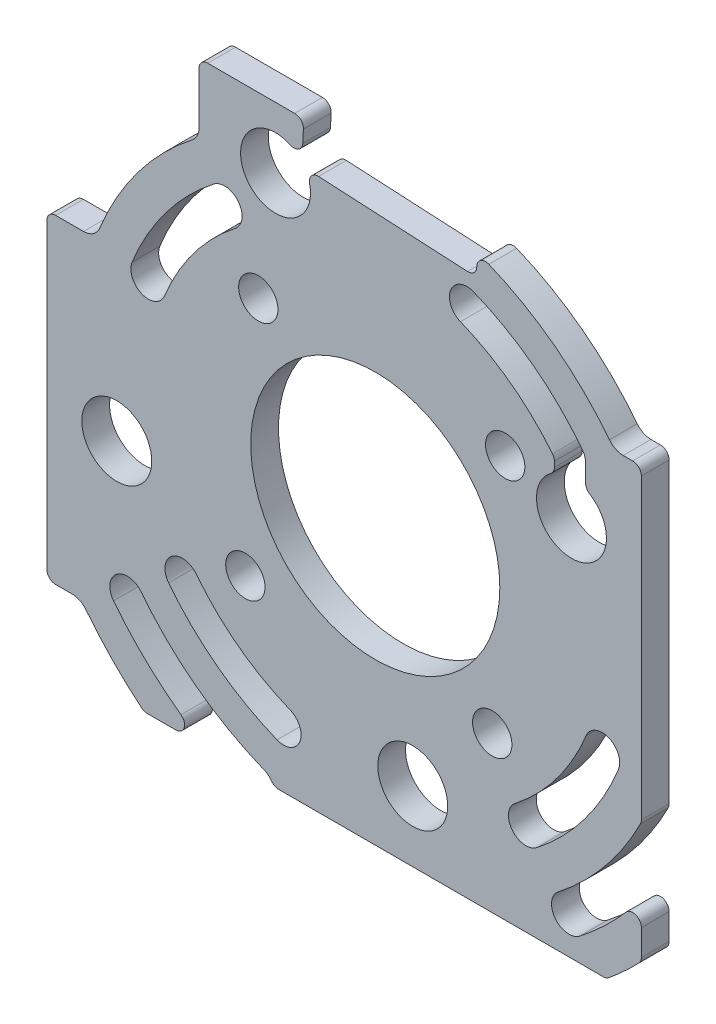
from build123d import *

# Parameters (mm, degrees)
SKETCH1_R               = 14.25
SKETCH1_R_2             = 4
BOSS_EXTRUDE1_DEPTH     = 3.175
M4_CLEARANCE_HOLE1_D    = 4.5
VENTHOLES_DEPTH         = 65.263003169
CIRPATTERN1_COUNT       = 4
CUT_EXTRUDE2_DEPTH      = 65.263003169
SKETCH7_W               = 68.017867909
SKETCH7_H               = 13.211155311
CUT_EXTRUDE3_DEPTH      = 65.263003169
CUT_EXTRUDE3_DEPTH_BACK = 65.263003169
CUT_EXTRUDE4_DEPTH      = 52.625675669
CUT_EXTRUDE4_DEPTH_BACK = 52.625675669
CUT_EXTRUDE5_DEPTH      = 52.625675669
CUT_EXTRUDE5_DEPTH_BACK = 52.625675669
FILLET1_R               = 1


with BuildPart() as part:
    # Sketch1 → Boss-Extrude1 (new body)
    with BuildSketch(Plane.XY):
        Polygon((30.444907858, -32.62998798), (-37.572960051, -32.62998798), (-37.572960051, 52.037732697), (30.444907858, 48.473067289), align=None)
        Circle(SKETCH1_R, mode=Mode.SUBTRACT)
        with Locations((-29.572960051, -7.37834899)):
            Circle(SKETCH1_R_2, mode=Mode.SUBTRACT)
        with Locations((-11.413340062, 28.261911978)):
            Circle(SKETCH1_R_2, mode=Mode.SUBTRACT)
        with Locations((22.444907858, 11.010272988)):
            Circle(SKETCH1_R_2, mode=Mode.SUBTRACT)
        with Locations((4.285287868, -24.62998798)):
            Circle(SKETCH1_R_2, mode=Mode.SUBTRACT)
    extrude(amount=BOSS_EXTRUDE1_DEPTH)

    # M4 Clearance Hole1 (through all)
    with Locations(Plane(origin=(0, 0, 0), x_dir=(-1, 0, 0), z_dir=(0, 0, -1))):
        with Locations((-14.86289651, 13.382612127), (13.382612127, 14.86289651), (14.86289651, -13.382612127), (-13.382612127, -14.86289651)):
            Hole(M4_CLEARANCE_HOLE1_D / 2)

    # Sketch4 → VentHoles (cut, through all)
    with BuildSketch(Plane.XY):
        with BuildLine():
            ThreePointArc((-23.395136062, 29.944408637), (-30.348149382, 22.86897088), (-35.232986474, 14.23505055))
            ThreePointArc((-35.232986474, 14.23505055), (-34.127831951, 11.631469654), (-31.524251055, 12.736624176))
            ThreePointArc((-31.524251055, 12.736624176), (-27.153607342, 20.461710787), (-20.932490161, 26.792365623))
            ThreePointArc((-20.932490161, 26.792365623), (-20.587791605, 29.59971008), (-23.395136062, 29.944408637))
        make_face()
        with BuildLine():
            ThreePointArc((-18.46984426, 23.640322608), (-23.959065301, 18.054450695), (-27.815515637, 11.238197802))
            ThreePointArc((-27.815515637, 11.238197802), (-26.710361115, 8.634616906), (-24.106780219, 9.739771429))
            ThreePointArc((-24.106780219, 9.739771429), (-20.764523261, 15.647190602), (-16.007198358, 20.488279594))
            ThreePointArc((-16.007198358, 20.488279594), (-15.662499802, 23.295624052), (-18.46984426, 23.640322608))
        make_face()
        with BuildLine():
            ThreePointArc((-42.65045731, 17.231903297), (-41.545302788, 14.628322401), (-38.941721892, 15.733476923))
            ThreePointArc((-38.941721892, 15.733476923), (-33.542691422, 25.276230972), (-25.857781964, 33.096451651))
            ThreePointArc((-25.857781964, 33.096451651), (-25.513083407, 35.903796109), (-28.320427865, 36.248494666))
            ThreePointArc((-28.320427865, 36.248494666), (-36.737233462, 27.683491065), (-42.65045731, 17.231903297))
        make_face()
    ventholes = extrude(amount=VENTHOLES_DEPTH, mode=Mode.SUBTRACT)

    # CirPattern1: VentHoles ×4 about axis
    cirpattern1_axis = Axis((0, 0, 0), (0, 0, 1))
    for i in range(1, CIRPATTERN1_COUNT):
        add(ventholes.rotate(cirpattern1_axis, i * 360 / CIRPATTERN1_COUNT), mode=Mode.SUBTRACT)

    # Sketch5 → Cut-Extrude2 (cut, through all)
    with BuildSketch(Plane.XY):
        Polygon((12.341413378, 44.414969502), (11.556374035, 29.43552648), (-8.41621666, 30.482245605), (-7.631177317, 45.461688626), align=None)
    extrude(amount=CUT_EXTRUDE2_DEPTH, mode=Mode.SUBTRACT)

    # Sketch7 → Cut-Extrude3 (cut, two sides)
    with BuildSketch(Plane.XY) as cut_extrude3_sk:
        with Locations((-3.564026097, 41.867489633)):
            Rectangle(SKETCH7_W, SKETCH7_H)
    extrude(amount=CUT_EXTRUDE3_DEPTH, mode=Mode.SUBTRACT)
    extrude(cut_extrude3_sk.sketch, amount=-CUT_EXTRUDE3_DEPTH_BACK, mode=Mode.SUBTRACT)


with BuildPart() as cut_extrude3_piece_1:
    # of the separate pieces the step leaves, piece 1, a body of its own (cut_extrude3_pieces)
    add(part.part.solids().sort_by_distance((26.443976335, -32.62998798, 0))[0])

    # Sketch9 → Cut-Extrude4 (cut, two sides)
    with BuildSketch(Plane.XY.offset(3.175)) as cut_extrude4_sk:
        with BuildLine():
            ThreePointArc((24.064301101, 17.238521309), (22.71543741, 15.347484158), (20.488279594, 16.007198358))
            Line((20.488279594, 16.007198358), (20.488279594, 14.499055847))
            ThreePointArc((20.488279594, 14.499055847), (22.256357537, 15.005826613), (24.064301101, 14.667808432))
            Line((24.064301101, 14.667808432), (24.064301101, 17.238521309))
        make_face()
    extrude(amount=CUT_EXTRUDE4_DEPTH, mode=Mode.SUBTRACT)
    extrude(cut_extrude4_sk.sketch, amount=-CUT_EXTRUDE4_DEPTH_BACK, mode=Mode.SUBTRACT)

    # Sketch10 → Cut-Extrude5 (cut, two sides)
    with BuildSketch(Plane.XY.offset(3.175)) as cut_extrude5_sk:
        Polygon((-37.572960051, -32.62998798), (-30.450066979, -32.62998798), (-34.672473159, -25.089104914), (-37.572960051, -25.089104914), align=None)
        Polygon((30.444907858, 36.985955285), (11.775698683, 36.985955285), (28.36838713, 20.163813112), (30.444907858, 20.163813112), align=None)
        with BuildLine():
            Line((-37.572960051, 18.768928392), (-37.572960051, 11.485837363))
            Line((-37.572960051, 11.485837363), (-33.378618764, 11.485837363))
            ThreePointArc((-33.378618764, 11.485837363), (-35.03669391, 12.367451556), (-35.232986474, 14.23505055))
            ThreePointArc((-35.232986474, 14.23505055), (-30.348149382, 22.86897088), (-23.395136062, 29.944408637))
            ThreePointArc((-23.395136062, 29.944408637), (-21.287070818, 30.165975222), (-20.163813112, 28.36838713))
            Line((-20.163813112, 28.36838713), (-20.163813112, 35.261911978))
            Line((-20.163813112, 35.261911978), (-25.17793724, 35.261911978))
            ThreePointArc((-25.17793724, 35.261911978), (-25.180933948, 34.073404246), (-25.857781964, 33.096451651))
            ThreePointArc((-25.857781964, 33.096451651), (-32.514369728, 26.586006868), (-37.572960051, 18.768928392))
        make_face()
    extrude(amount=CUT_EXTRUDE5_DEPTH, mode=Mode.SUBTRACT)
    extrude(cut_extrude5_sk.sketch, amount=-CUT_EXTRUDE5_DEPTH_BACK, mode=Mode.SUBTRACT)

    # Fillet1
    fillet1_edges = [cut_extrude3_piece_1.edges().sort_by_distance(p)[0] for p in [
        (30.444907858, -28.932811573, 1.5875),
        (26.443976335, -32.62998798, 1.5875),
        (-11.631234454, -32.62998798, 1.5875),
        (-19.475212051, -32.62998798, 1.5875),
        (11.714368197, 32.450234687, 1.5875),
        (-8.16572496, 35.261911978, 1.5875),
        (-26.443976335, -32.62998798, 1.5875),
        (11.556374035, 29.43552648, 1.5875),
        (-8.395017915, 30.886741766, 1.5875),
        (-8.07427182, 30.464325035, 1.5875),
        (20.488279594, 16.007198358, 1.5875),
        (20.488279594, 14.499055847, 1.5875),
        (24.064301101, 14.667808432, 1.5875),
        (30.444907858, -22.739999682, 1.5875),
        (-37.572960051, -25.089104914, 1.5875),
        (30.444907858, -15.136300259, 1.5875),
        (30.444907858, 20.163813112, 1.5875),
        (-20.163813112, 35.261911978, 1.5875),
        (-37.572960051, 11.485837363, 1.5875),
    ]]
    fillet(fillet1_edges, radius=FILLET1_R)


with BuildPart() as cut_extrude3_piece_2:
    # of the separate pieces the step leaves, piece 2, a body of its own (cut_extrude3_pieces)
    add(part.part.solids().sort_by_distance((30.444907858, 48.473067289, 0))[0])


with BuildPart() as cut_extrude3_piece_3:
    # of the separate pieces the step leaves, piece 3, a body of its own (cut_extrude3_pieces)
    add(part.part.solids().sort_by_distance((-37.572960051, 35.261911978, 0))[0])


with BuildPart() as cut_extrude3_piece_4:
    # of the separate pieces the step leaves, piece 4, a body of its own (cut_extrude3_pieces)
    add(part.part.solids().sort_by_distance((29.539762417, 35.261911978, 0))[0])


with BuildPart() as cut_extrude3_piece_5:
    # of the separate pieces the step leaves, piece 5, a body of its own (cut_extrude3_pieces)
    add(part.part.solids().sort_by_distance((11.86172196, 35.261911978, 0))[0])


solid = cut_extrude3_piece_1.part
